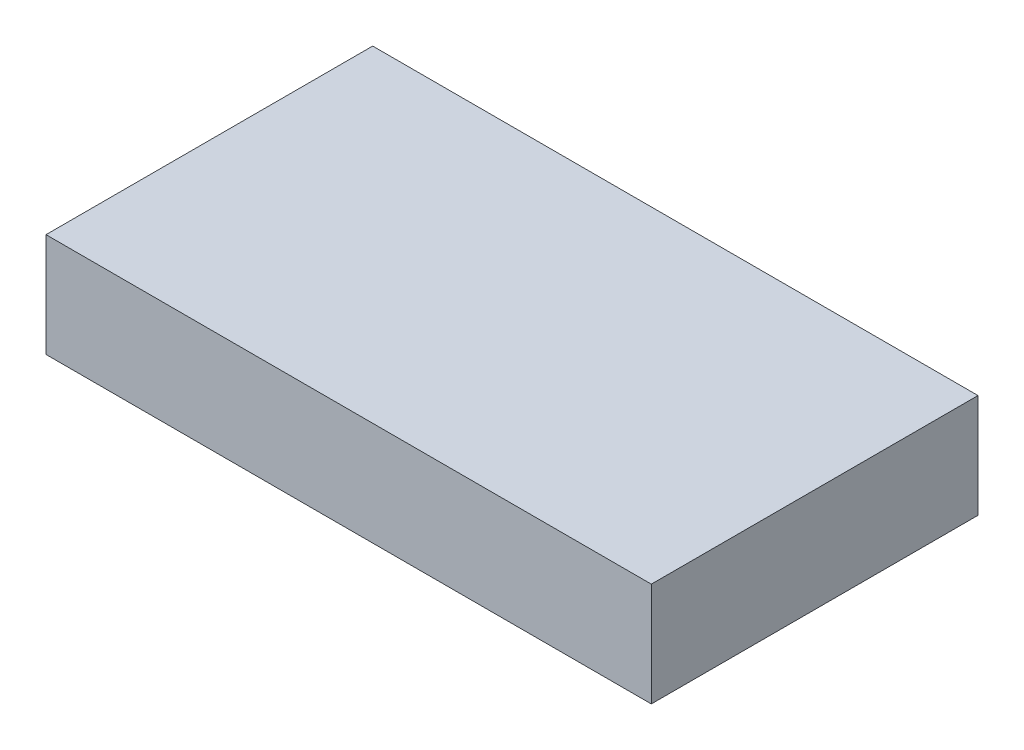
from build123d import *

# Parameters (mm, degrees)
SPH_SKETCH_W      = 15.75
SPH_SKETCH_H      = 8.5
SPH_EXTRUDE_DEPTH = 2.7


with BuildPart() as part:
    # SPH Sketch → SPH Extrude (new body)
    with BuildSketch(Plane(origin=(0, 0, 0), x_dir=(1, 0, 0), z_dir=(0, 1, 0))):
        with Locations((7.875, 4.25)):
            Rectangle(SPH_SKETCH_W, SPH_SKETCH_H)
    extrude(amount=SPH_EXTRUDE_DEPTH)


solid = part.part
